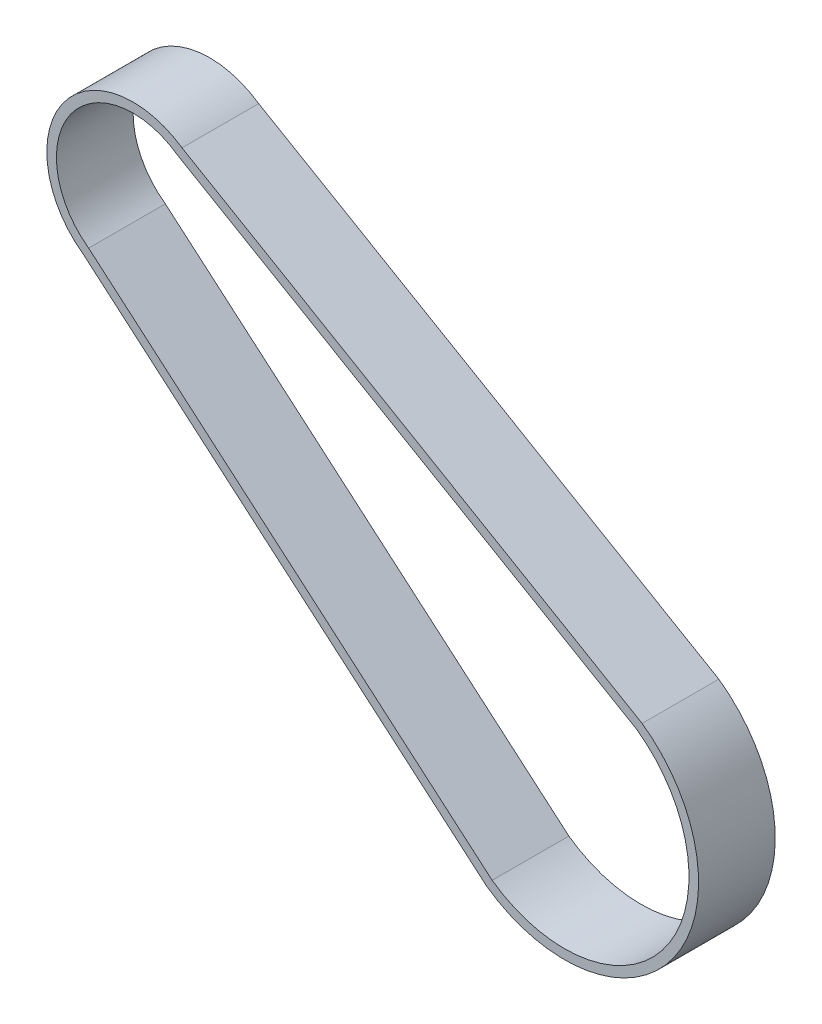
from build123d import *

# Parameters (mm, degrees)
BOSS_EXTRU_1_DEPTH = 8


with BuildPart() as part:
    # Esquisse1 → Boss.-Extru.1 (new body)
    with BuildSketch(Plane.XY):
        with BuildLine():
            Line((8.113333009, 11.409374544), (-39.892627503, 39.410448447))
            ThreePointArc((-39.892627503, 39.410448447), (-52.372722195, 37.161682616), (-50.215714077, 24.665402079))
            Line((-50.215714077, 24.665402079), (-8.113333009, -11.409374544))
            ThreePointArc((-8.113333009, -11.409374544), (11.409374544, -8.113333009), (8.113333009, 11.409374544))
        make_face()
        with BuildLine():
            ThreePointArc((-49.636190291, 25.480357403), (-51.519642597, 36.636190291), (-40.363809709, 38.519642597))
            Line((-40.363809709, 38.519642597), (7.533809223, 10.594419219))
            ThreePointArc((7.533809223, 10.594419219), (10.594419219, -7.533809223), (-7.533809223, -10.594419219))
            Line((-7.533809223, -10.594419219), (-49.636190291, 25.480357403))
        make_face(mode=Mode.SUBTRACT)
    extrude(amount=BOSS_EXTRU_1_DEPTH)


solid = part.part
